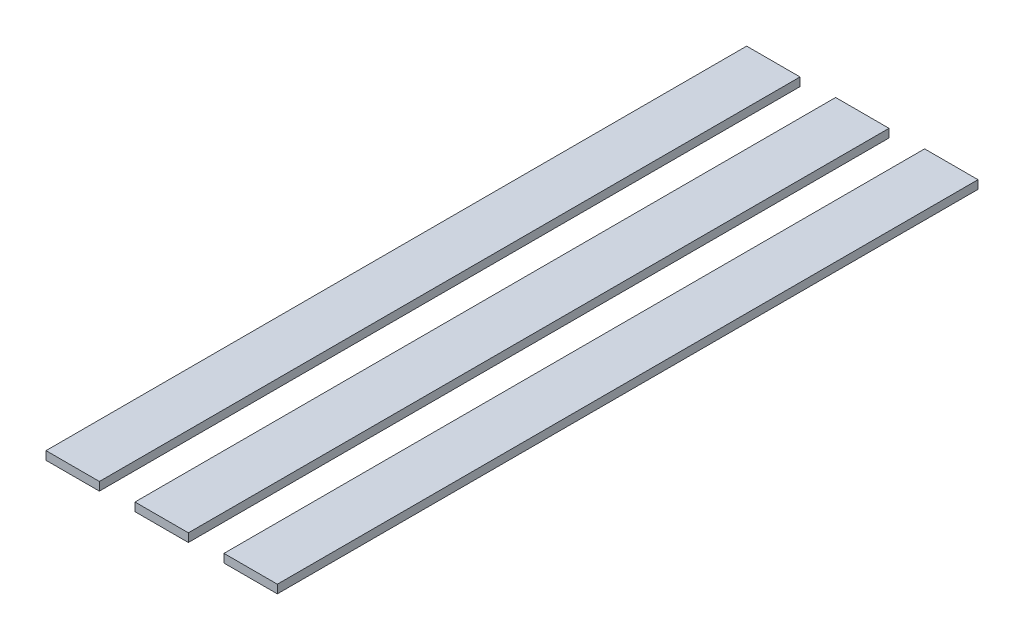
from build123d import *

# Parameters (mm, degrees)
CROQUIS1_W                = 38.1
CROQUIS1_H                = 6
SALIENTE_EXTRUIR1_DEPTH   = 500
SALIENTE_EXTRUIR1_2_DEPTH = 500
SALIENTE_EXTRUIR1_3_DEPTH = 500


with BuildPart() as part:
    # Croquis1 → Saliente-Extruir1 (new body)
    with BuildSketch(Plane.XY):
        Rectangle(CROQUIS1_W, CROQUIS1_H)
    extrude(amount=SALIENTE_EXTRUIR1_DEPTH)


with BuildPart() as body_2:
    # Croquis1 → Saliente-Extruir1 2 (new body)
    with BuildSketch(Plane.XY):
        with Locations((-63.5, 0)):
            Rectangle(CROQUIS1_W, CROQUIS1_H)
    extrude(amount=SALIENTE_EXTRUIR1_2_DEPTH)


with BuildPart() as body_3:
    # Croquis1 → Saliente-Extruir1 3 (new body)
    with BuildSketch(Plane.XY):
        with Locations((63.5, 0)):
            Rectangle(CROQUIS1_W, CROQUIS1_H)
    extrude(amount=SALIENTE_EXTRUIR1_3_DEPTH)


solid = Compound([part.part, body_2.part, body_3.part])
